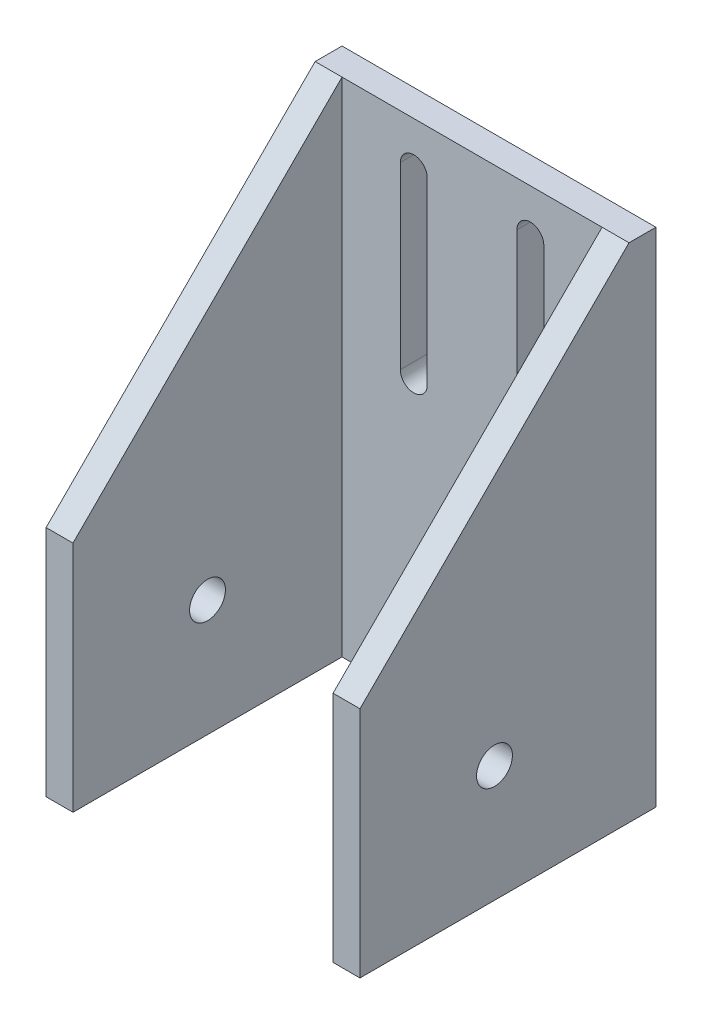
from build123d import *

# Parameters (mm, degrees)
SKETCH1_W               = 35
SKETCH1_H               = 56
BOSS_EXTRUDE1_DEPTH     = 3
SKETCH2_W               = 3
SKETCH2_H               = 26
BOSS_EXTRUDE2_DEPTH     = 30
SKETCH4_R               = 2
CUT_EXTRUDE1_DEPTH      = 33
CUT_EXTRUDE1_DEPTH_BACK = 4
BOSS_EXTRUDE3_DEPTH     = 35
SKETCH6_W               = 29
SKETCH6_H               = 30
CUT_EXTRUDE2_DEPTH      = 30


with BuildPart() as part:
    # Sketch1 → Boss-Extrude1 (new body)
    with BuildSketch(Plane.XY):
        Rectangle(SKETCH1_W, SKETCH1_H)
        with BuildLine():
            Line((-5, 23), (-5, 3))
            ThreePointArc((-5, 3), (-6.5, 1.5), (-8, 3))
            Line((-8, 3), (-8, 23))
            ThreePointArc((-8, 23), (-6.5, 24.5), (-5, 23))
        make_face(mode=Mode.SUBTRACT)
        with BuildLine():
            Line((5, 23), (5, 3))
            ThreePointArc((5, 3), (6.5, 1.5), (8, 3))
            Line((8, 3), (8, 23))
            ThreePointArc((8, 23), (6.5, 24.5), (5, 23))
        make_face(mode=Mode.SUBTRACT)
    extrude(amount=BOSS_EXTRUDE1_DEPTH)

    # Sketch2 → Boss-Extrude2 (add)
    with BuildSketch(Plane.XY.offset(3)):
        with Locations((-16, -15)):
            Rectangle(SKETCH2_W, SKETCH2_H)
        with Locations((16, -15)):
            Rectangle(SKETCH2_W, SKETCH2_H)
    extrude(amount=BOSS_EXTRUDE2_DEPTH)

    # Sketch4 → Cut-Extrude1 (cut, two sides)
    with BuildSketch(Plane.ZY.offset(-14.5)) as cut_extrude1_sk:
        with Locations((18, -15)):
            Circle(SKETCH4_R)
    extrude(amount=CUT_EXTRUDE1_DEPTH, mode=Mode.SUBTRACT)
    extrude(cut_extrude1_sk.sketch, amount=-CUT_EXTRUDE1_DEPTH_BACK, mode=Mode.SUBTRACT)

    # Sketch5 → Boss-Extrude3 (add, through all)
    with BuildSketch(Plane.ZY.offset(17.5)):
        Polygon((3, 28), (33, -2), (3, -2), align=None)
    extrude(amount=-BOSS_EXTRUDE3_DEPTH)

    # Sketch6 → Cut-Extrude2 (cut)
    with BuildSketch(Plane.XY.offset(33)):
        with Locations((0, 13)):
            Rectangle(SKETCH6_W, SKETCH6_H)
    extrude(amount=-CUT_EXTRUDE2_DEPTH, mode=Mode.SUBTRACT)


solid = part.part
